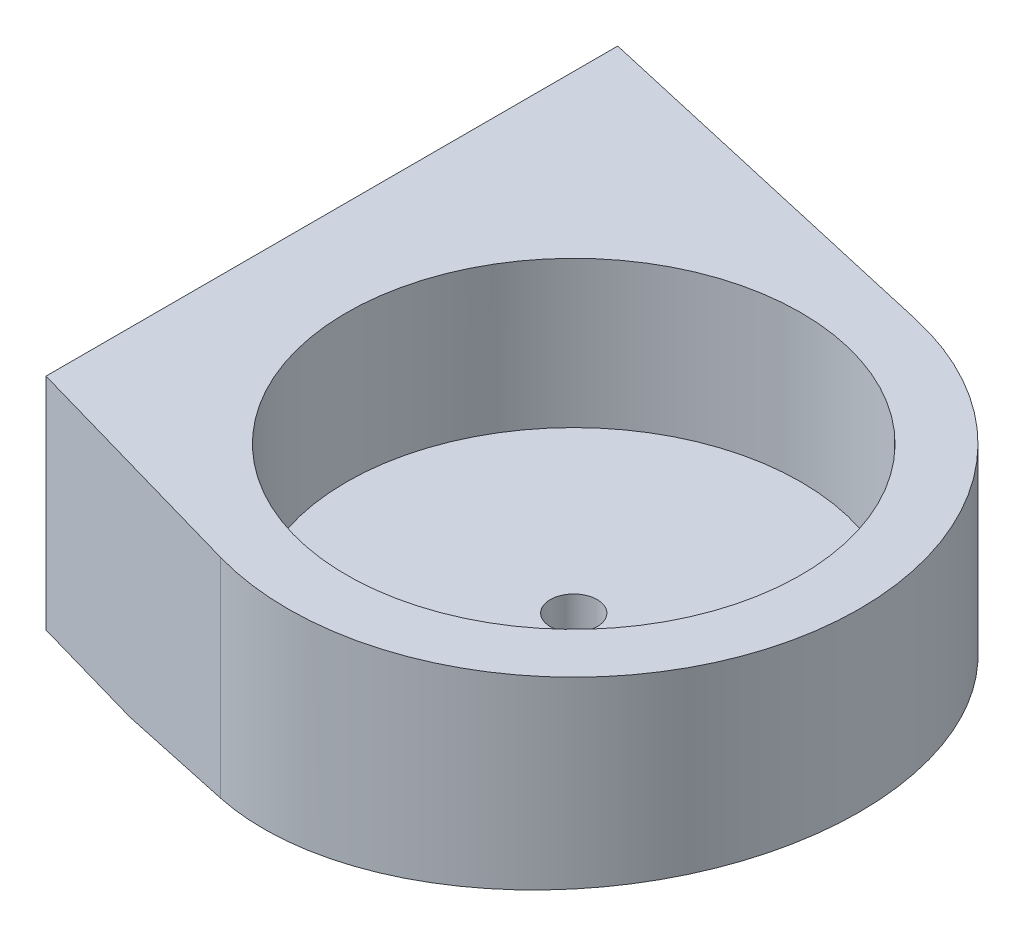
from build123d import *

# Parameters (mm, degrees)
SKETCH1_R               = 15.5
BOSS_EXTRUDE1_DEPTH     = 5
SKETCH2_R               = 15.5
BOSS_EXTRUDE2_DEPTH     = 15
CUT_EXTRUDE7_DEPTH      = 20.5
CUT_EXTRUDE7_DEPTH_BACK = 26
SKETCH18_R              = 1.6
CUT_EXTRUDE8_DEPTH      = 6
SKETCH19_R              = 2.05
CUT_EXTRUDE9_DEPTH      = 6
CUT_EXTRUDE10_REACH     = 4
SKETCH20_R              = 4


with BuildPart() as part:
    # Sketch1 → Boss-Extrude1 (new body)
    with BuildSketch(Plane(origin=(0, 0, 0), x_dir=(1, 0, 0), z_dir=(0, 1, 0))):
        Circle(SKETCH1_R)
    extrude(amount=BOSS_EXTRUDE1_DEPTH)

    # Sketch2 → Boss-Extrude2 (add)
    with BuildSketch(Plane.XZ):
        with BuildLine():
            Line((-22, -25), (4.323483194, -19.014665211))
            ThreePointArc((4.323483194, -19.014665211), (18.889988887, 4.839247858), (-5.351429285, 18.751325409))
            Line((-5.351429285, 18.751325409), (-22, 14))
            Line((-22, 14), (-22, -25))
        make_face()
        Circle(SKETCH2_R, mode=Mode.SUBTRACT)
    extrude(amount=-BOSS_EXTRUDE2_DEPTH)

    # Sketch17 → Cut-Extrude7 (cut, two sides)
    with BuildSketch(Plane.XY) as cut_extrude7_sk:
        Polygon((19.5, 0), (-14, 0), (19.5, 3), align=None)
    extrude(amount=CUT_EXTRUDE7_DEPTH, mode=Mode.SUBTRACT)
    extrude(cut_extrude7_sk.sketch, amount=-CUT_EXTRUDE7_DEPTH_BACK, mode=Mode.SUBTRACT)

    # Sketch18 → Cut-Extrude8 (cut, through all)
    with BuildSketch(Plane(origin=(0, 5, 0), x_dir=(1, 0, 0), z_dir=(0, 1, 0))):
        Circle(SKETCH18_R)
    extrude(amount=-CUT_EXTRUDE8_DEPTH, mode=Mode.SUBTRACT)

    # Sketch19 → Cut-Extrude9 (cut)
    with BuildSketch(Plane.XZ):
        with Locations((-18, -5.5)):
            Circle(SKETCH19_R)
    extrude(amount=-CUT_EXTRUDE9_DEPTH, mode=Mode.SUBTRACT)

    # Sketch20 → Cut-Extrude10 (cut, up to next)
    with BuildSketch(Plane(origin=(0, 2, 0), x_dir=(1, 0, 0), z_dir=(0, 1, 0)), mode=Mode.PRIVATE) as cut_extrude10_sk1:
        Circle(SKETCH20_R)
    cut_extrude10_tool1 = extrude(cut_extrude10_sk1.sketch, amount=-CUT_EXTRUDE10_REACH, mode=Mode.PRIVATE) & part.part
    add(cut_extrude10_tool1.solids().sort_by_distance((0, 2, 0))[0], mode=Mode.SUBTRACT)


solid = part.part
